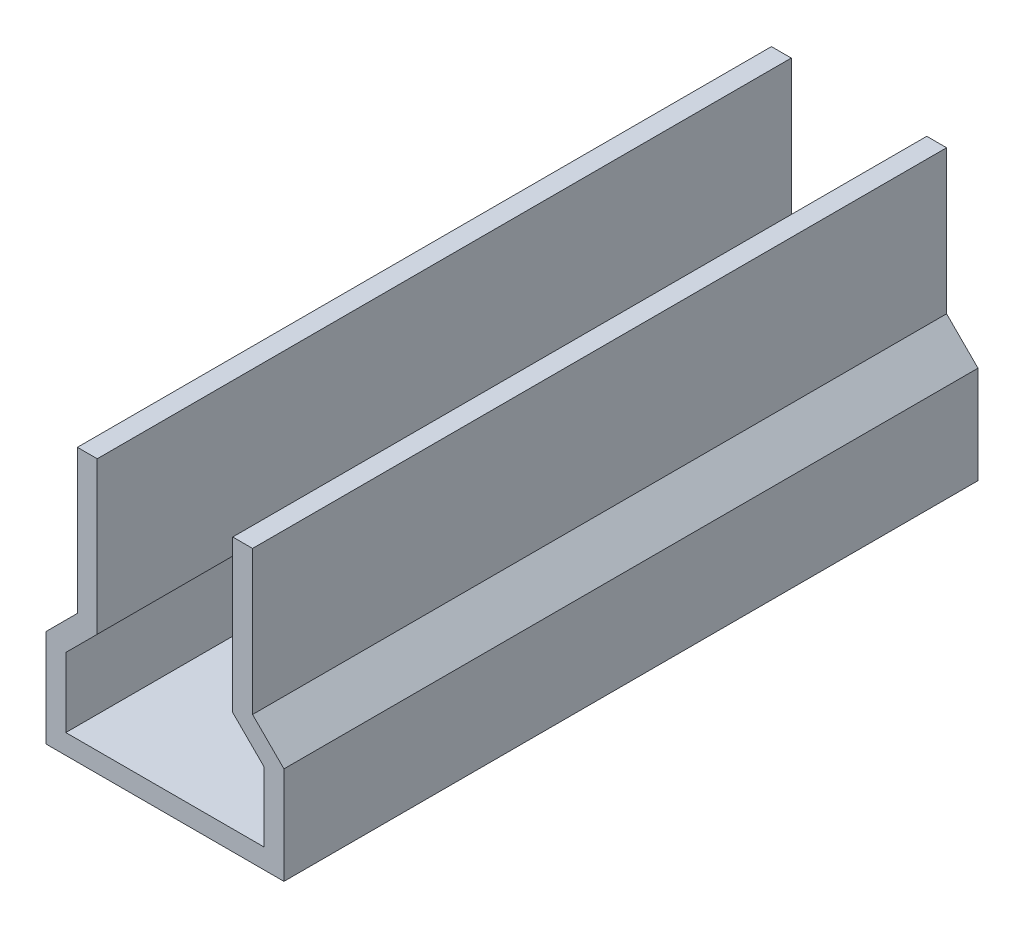
from build123d import *

# Parameters (mm, degrees)
BOSS_EXTRUDE1_DEPTH     = 105
SKETCH2_W               = 20.5
SKETCH2_H               = 3
CUT_EXTRUDE1_DEPTH      = 1
CUT_EXTRUDE1_DEPTH_BACK = 106


with BuildPart() as part:
    # Sketch1 → Boss-Extrude1 (new body)
    with BuildSketch(Plane.XY):
        Polygon((18, 11.742640687), (13.25, 16.492640687), (13.25, 38.25), (-13.25, 38.25), (-13.25, 16.492640687), (-18, 11.742640687), (-18, -3), (18, -3), align=None)
        Polygon((15, 0), (-15, 0), (-15, 10.5), (-10.25, 15.25), (-10.25, 35.25), (10.25, 35.25), (10.25, 15.25), (15, 10.5), align=None, mode=Mode.SUBTRACT)
    extrude(amount=BOSS_EXTRUDE1_DEPTH)

    # Sketch2 → Cut-Extrude1 (cut, two sides)
    with BuildSketch(Plane.XY.offset(105)) as cut_extrude1_sk:
        with Locations((0, 36.75)):
            Rectangle(SKETCH2_W, SKETCH2_H)
    extrude(amount=CUT_EXTRUDE1_DEPTH, mode=Mode.SUBTRACT)
    extrude(cut_extrude1_sk.sketch, amount=-CUT_EXTRUDE1_DEPTH_BACK, mode=Mode.SUBTRACT)


solid = part.part
